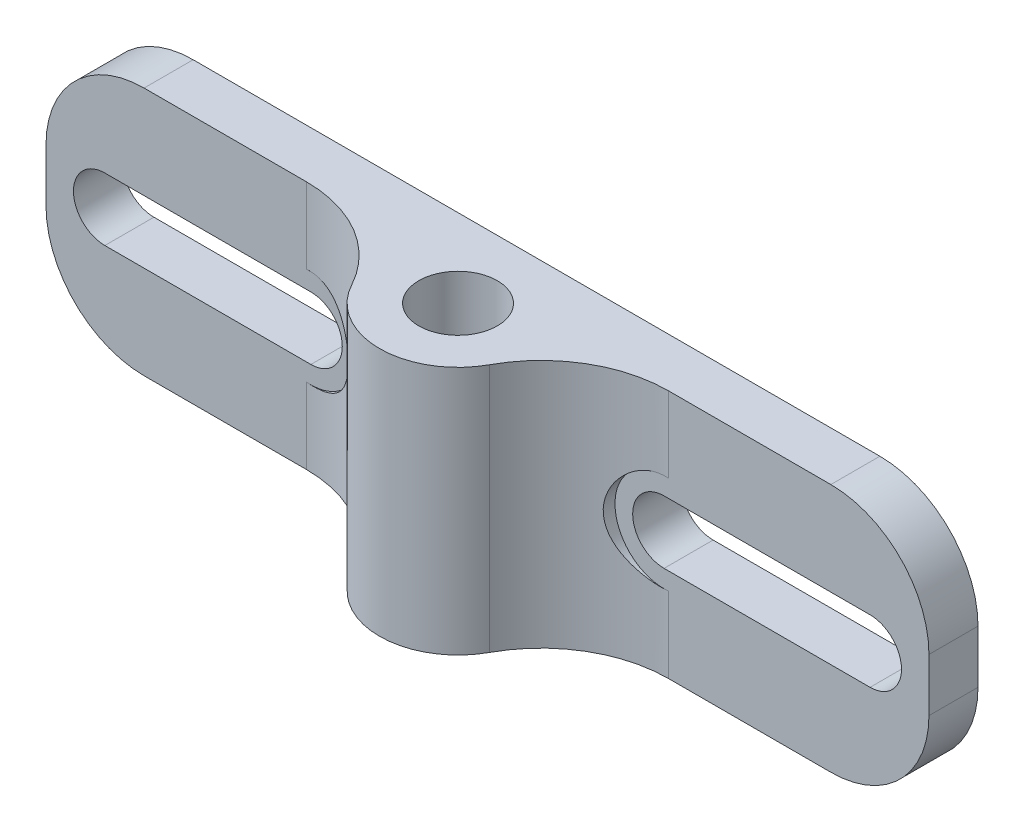
from build123d import *

# Parameters (mm, degrees)
SKETCH1_R               = 4
BOSS_EXTRUDE1_DEPTH     = 25.4
FILLET1_R               = 13
CUT_EXTRUDE1_DEPTH      = 12
CUT_EXTRUDE1_DEPTH_BACK = 6
SKETCH3_R               = 5
CUT_EXTRUDE2_DEPTH      = 25.4
FILLET2_R               = 10


with BuildPart() as part:
    # Sketch1 → Boss-Extrude1 (new body)
    with BuildSketch(Plane(origin=(0, 0, 0), x_dir=(1, 0, 0), z_dir=(0, 1, 0))):
        with BuildLine():
            Line((-45, 0), (45, 0))
            Line((45, 0), (45, -5))
            Line((45, -5), (7.416198487, -5))
            ThreePointArc((7.416198487, -5), (0, -16), (-7.416198487, -5))
            Line((-7.416198487, -5), (-45, -5))
            Line((-45, -5), (-45, 0))
        make_face()
        with Locations((0, -8)):
            Circle(SKETCH1_R, mode=Mode.SUBTRACT)
    extrude(amount=BOSS_EXTRUDE1_DEPTH)

    # Fillet1
    fillet1_edges = [part.edges().sort_by_distance(p)[0] for p in [
        (7.416198487, 12.7, 5),
        (-7.416198487, 12.7, 5),
    ]]
    fillet(fillet1_edges, radius=FILLET1_R)

    # Sketch2 → Cut-Extrude1 (cut, two sides)
    with BuildSketch(Plane.XY.offset(5)) as cut_extrude1_sk:
        with BuildLine():
            Line((-39, 15.9), (-18, 15.9))
            ThreePointArc((-18, 15.9), (-14.8, 12.7), (-18, 9.5))
            Line((-18, 9.5), (-39, 9.5))
            ThreePointArc((-39, 9.5), (-42.2, 12.7), (-39, 15.9))
        make_face()
        with BuildLine():
            Line((39, 9.5), (18, 9.5))
            ThreePointArc((18, 9.5), (14.8, 12.7), (18, 15.9))
            Line((18, 15.9), (39, 15.9))
            ThreePointArc((39, 15.9), (42.2, 12.7), (39, 9.5))
        make_face()
    extrude(amount=CUT_EXTRUDE1_DEPTH, mode=Mode.SUBTRACT)
    extrude(cut_extrude1_sk.sketch, amount=-CUT_EXTRUDE1_DEPTH_BACK, mode=Mode.SUBTRACT)

    # Sketch3 → Cut-Extrude2 (cut)
    with BuildSketch(Plane.XY.offset(5)):
        with Locations((-18, 12.7)):
            Circle(SKETCH3_R)
        with Locations((18, 12.7)):
            Circle(SKETCH3_R)
    extrude(amount=CUT_EXTRUDE2_DEPTH, mode=Mode.SUBTRACT)

    # Fillet2
    fillet2_edges = [part.edges().sort_by_distance(p)[0] for p in [
        (-45, 25.4, 2.5),
        (45, 25.4, 2.5),
        (-45, 0, 2.5),
        (45, 0, 2.5),
    ]]
    fillet(fillet2_edges, radius=FILLET2_R)


solid = part.part
